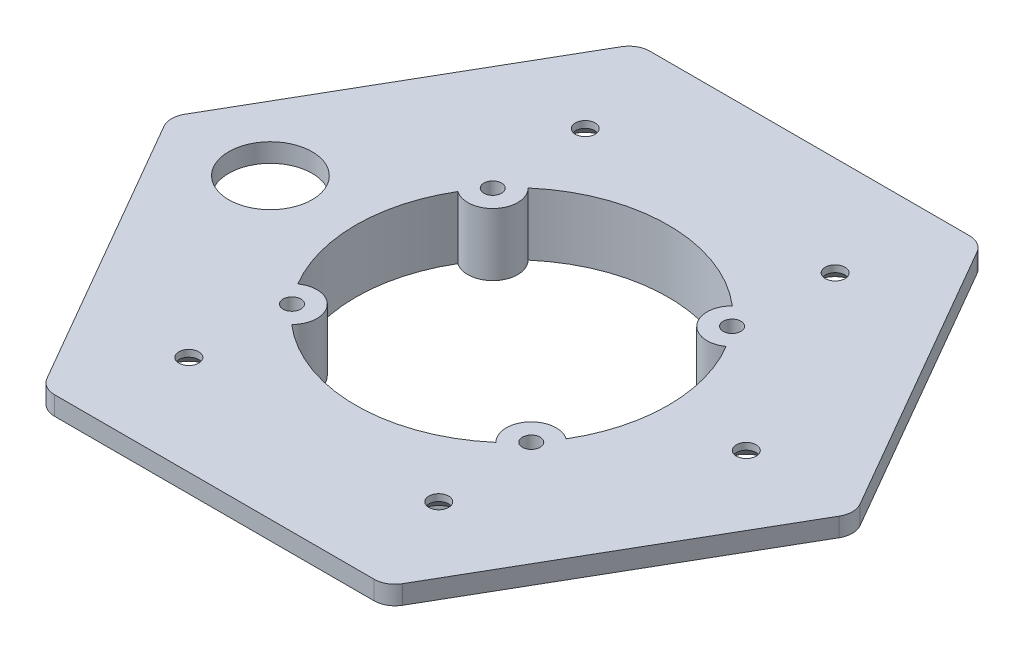
from build123d import *

# Parameters (mm, degrees)
SKETCH_1_R                  = 0.95
EXTRUDE_1_DEPTH             = 1.8
FILLET_1_R                  = 2
HOLE_WIZARD_M2_1_AT_2_COUNT = 2
HOLE_WIZARD_M2_1_AT_2_PITCH = 24
HOLE_WIZARD_M2_1_AT_3_COUNT = 2
HOLE_WIZARD_M2_1_AT_3_PITCH = 39.40177661
HOLE_WIZARD_M2_1_AT_4_COUNT = 2
HOLE_WIZARD_M2_1_AT_4_PITCH = 45
HOLE_WIZARD_M2_1_AT_5_COUNT = 2
HOLE_WIZARD_M2_1_AT_5_PITCH = 38.065732621
HOLE_WIZARD_M2_1_AT_6_COUNT = 2
HOLE_WIZARD_M2_1_AT_6_PITCH = 21.737065119
SKETCH_4_R                  = 17.25
SKETCH_4_R_2                = 15
EXTRUDE_2_DEPTH             = 4.2
SKETCH_4_2_R                = 15
CUT_EXTRUDE_2_DEPTH         = 3.5
SKETCH_7_R                  = 0.85
EXTRUDE_3_DEPTH             = 6
SKETCH_7_2_R                = 0.85
CUT_EXTRUDE_4_DEPTH         = 7
SKETCH_8_R                  = 4
CUT_EXTRUDE_5_DEPTH         = 10


with BuildPart() as part:
    # Sketch 1 → Extrude 1 (new body)
    with BuildSketch(Plane(origin=(0, 0, 0), x_dir=(1, 0, 0), z_dir=(0, 1, 0))):
        Polygon((33, 0), (16.5, 28.578838325), (-16.5, 28.578838325), (-33, 0), (-16.5, -28.578838325), (16.5, -28.578838325), align=None)
        with Locations(Location((-12, 19.032866311, 0), (0, 0, 270))):  # turned: the seam where the file's is
            Circle(SKETCH_1_R, mode=Mode.SUBTRACT)
        with Locations(Location((-12, -19.032866311, 0), (0, 0, 90))):  # turned: the seam where the file's is
            Circle(SKETCH_1_R, mode=Mode.SUBTRACT)
        with Locations(Location((-22.5, 0, 0), (0, 0, 270))):  # turned: the seam where the file's is
            Circle(SKETCH_1_R, mode=Mode.SUBTRACT)
        with Locations(Location((22.5, 0, 0), (0, 0, 90))):  # turned: the seam where the file's is
            Circle(SKETCH_1_R, mode=Mode.SUBTRACT)
        with Locations(Location((12, -19.032866311, 0), (0, 0, 270))):  # turned: the seam where the file's is
            Circle(SKETCH_1_R, mode=Mode.SUBTRACT)
        with Locations(Location((12, 19.032866311, 0), (0, 0, 90))):  # turned: the seam where the file's is
            Circle(SKETCH_1_R, mode=Mode.SUBTRACT)
    extrude(amount=EXTRUDE_1_DEPTH)

    # Fillet 1
    fillet_1_edges = [part.edges().sort_by_distance(p)[0] for p in [
        (16.5, 0.9, 28.578838325),
        (-16.5, 0.9, 28.578838325),
        (-33, 0.9, 0),
        (-16.5, 0.9, -28.578838325),
        (16.5, 0.9, -28.578838325),
        (33, 0.9, 0),
    ]]
    fillet(fillet_1_edges, radius=FILLET_1_R)

    # Sketch 3 → Hole Wizard M2 _1 (revolve, cut)
    with BuildSketch(Plane(origin=(12, 0, -19.032866311), x_dir=(0, 0, -1), z_dir=(1, 0, 0))):
        Polygon((0, 0), (0, 1.8), (0.9, 1.8), (0.9, 1.2), (2.1, 0), align=None)
    hole_wizard_m2_1 = revolve(axis=Axis((12, -6.35, -19.032866311), (0, 1, 0)), mode=Mode.SUBTRACT)

    # Hole Wizard M2 _1 at 2: Hole Wizard M2 _1 ×2
    with Locations(*[(-i * HOLE_WIZARD_M2_1_AT_2_PITCH, 0, 0) for i in range(1, HOLE_WIZARD_M2_1_AT_2_COUNT)]):
        add(hole_wizard_m2_1, mode=Mode.SUBTRACT)

    # Hole Wizard M2 _1 at 3: Hole Wizard M2 _1 ×2
    with Locations(*[Vector(-0.875595036, 0, 0.483045892) * (i * HOLE_WIZARD_M2_1_AT_3_PITCH) for i in range(1, HOLE_WIZARD_M2_1_AT_3_COUNT)]):
        add(hole_wizard_m2_1, mode=Mode.SUBTRACT)

    # Hole Wizard M2 _1 at 4: Hole Wizard M2 _1 ×2
    with Locations(*[Vector(-0.533333333, 0, 0.845905169) * (i * HOLE_WIZARD_M2_1_AT_4_PITCH) for i in range(1, HOLE_WIZARD_M2_1_AT_4_COUNT)]):
        add(hole_wizard_m2_1, mode=Mode.SUBTRACT)

    # Hole Wizard M2 _1 at 5: Hole Wizard M2 _1 ×2
    with Locations(*[(0, 0, i * HOLE_WIZARD_M2_1_AT_5_PITCH) for i in range(1, HOLE_WIZARD_M2_1_AT_5_COUNT)]):
        add(hole_wizard_m2_1, mode=Mode.SUBTRACT)

    # Hole Wizard M2 _1 at 6: Hole Wizard M2 _1 ×2
    with Locations(*[Vector(0.483045892, 0, 0.875595036) * (i * HOLE_WIZARD_M2_1_AT_6_PITCH) for i in range(1, HOLE_WIZARD_M2_1_AT_6_COUNT)]):
        add(hole_wizard_m2_1, mode=Mode.SUBTRACT)

    # Sketch 4 → Extrude 2 (add)
    with BuildSketch(Plane.XZ):
        with Locations(Location((0, 0, 0), (0, 0, 90))):  # turned: the seam where the file's is
            Circle(SKETCH_4_R)
        with Locations(Location((0, 0, 0), (0, 0, 270))):  # turned: the seam where the file's is
            Circle(SKETCH_4_R_2, mode=Mode.SUBTRACT)
    extrude(amount=EXTRUDE_2_DEPTH)

    # Sketch 4_2 → Cut-Extrude 2 (cut)
    with BuildSketch(Plane.XZ):
        with Locations(Location((0, 0, 0), (0, 0, 90))):  # turned: the seam where the file's is
            Circle(SKETCH_4_2_R)
    extrude(amount=-CUT_EXTRUDE_2_DEPTH, mode=Mode.SUBTRACT)

    # Sketch 7 → Extrude 3 (add)
    with BuildSketch(Plane.XZ.offset(4.2)):
        with BuildLine():
            ThreePointArc((-13.77195188, 10.387292305), (-9.652159983, 8.099123882), (-12.620960341, 11.758990606))
            ThreePointArc((-12.620960341, 11.758990606), (-13.214266644, 11.088086267), (-13.77195188, 10.387292305))
        make_face()
        with Locations((-11.490666647, 9.641814145)):
            Circle(SKETCH_7_R, mode=Mode.SUBTRACT)
        with BuildLine():
            ThreePointArc((13.77195188, 10.387292305), (9.652159983, 8.099123882), (12.620960341, 11.758990606))
            ThreePointArc((12.620960341, 11.758990606), (13.214266644, 11.088086267), (13.77195188, 10.387292305))
        make_face()
        with Locations((11.490666647, 9.641814145)):
            Circle(SKETCH_7_R, mode=Mode.SUBTRACT)
        with BuildLine():
            ThreePointArc((13.77195188, -10.387292305), (9.652159983, -8.099123882), (12.620960341, -11.758990606))
            ThreePointArc((12.620960341, -11.758990606), (13.214266644, -11.088086267), (13.77195188, -10.387292305))
        make_face()
        with Locations((11.490666647, -9.641814145)):
            Circle(SKETCH_7_R, mode=Mode.SUBTRACT)
        with BuildLine():
            ThreePointArc((-13.77195188, -10.387292305), (-9.652159983, -8.099123882), (-12.620960341, -11.758990606))
            ThreePointArc((-12.620960341, -11.758990606), (-13.214266644, -11.088086267), (-13.77195188, -10.387292305))
        make_face()
        with Locations((-11.490666647, -9.641814145)):
            Circle(SKETCH_7_R, mode=Mode.SUBTRACT)
    extrude(amount=-EXTRUDE_3_DEPTH)

    # Sketch 7_2 → Cut-Extrude 4 (cut, through all)
    with BuildSketch(Plane.XZ.offset(4.2)):
        with Locations(Location((-11.490666647, 9.641814145, 0), (0, 0, 270))):  # turned: the seam where the file's is
            Circle(SKETCH_7_2_R)
        with Locations(Location((11.490666647, 9.641814145, 0), (0, 0, 90))):  # turned: the seam where the file's is
            Circle(SKETCH_7_2_R)
        with Locations(Location((11.490666647, -9.641814145, 0), (0, 0, 270))):  # turned: the seam where the file's is
            Circle(SKETCH_7_2_R)
        with Locations(Location((-11.490666647, -9.641814145, 0), (0, 0, 90))):  # turned: the seam where the file's is
            Circle(SKETCH_7_2_R)
    extrude(amount=-CUT_EXTRUDE_4_DEPTH, mode=Mode.SUBTRACT)

    # Sketch 8 → Cut-Extrude 5 (cut)
    with BuildSketch(Plane(origin=(0, 1.8, 0), x_dir=(1, 0, 0), z_dir=(0, 1, 0))):
        with Locations(Location((-23.2, 0, 0), (0, 0, 270))):  # turned: the seam where the file's is
            Circle(SKETCH_8_R)
    extrude(amount=-CUT_EXTRUDE_5_DEPTH, mode=Mode.SUBTRACT)


solid = part.part
